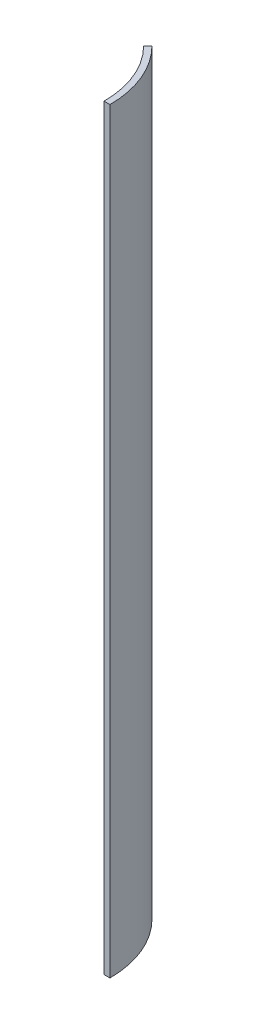
from build123d import *

# Parameters (mm, degrees)
SKETCH2_W          = 4.064
SKETCH2_H          = 520.7
SKETCH3_W          = 133.284946351
SKETCH3_H          = 614.773092451
CUT_REVOLVE1_ANGLE = 315


with BuildPart() as part:
    # Sketch2 → Revolve1 (revolve)
    with BuildSketch(Plane.XY):
        with Locations((-67.818, 260.35)):
            Rectangle(SKETCH2_W, SKETCH2_H)
    revolve(axis=Axis((0, 819.187021794, 0), (0, -1, 0)))

    # Sketch3 → Cut-Revolve1 (revolve, cut)
    with BuildSketch(Plane.XY):
        with Locations((66.642473176, 255.432223208)):
            Rectangle(SKETCH3_W, SKETCH3_H)
    revolve(axis=Axis((0, 819.187021794, 0), (0, -1, 0)), revolution_arc=CUT_REVOLVE1_ANGLE, mode=Mode.SUBTRACT)


solid = part.part
